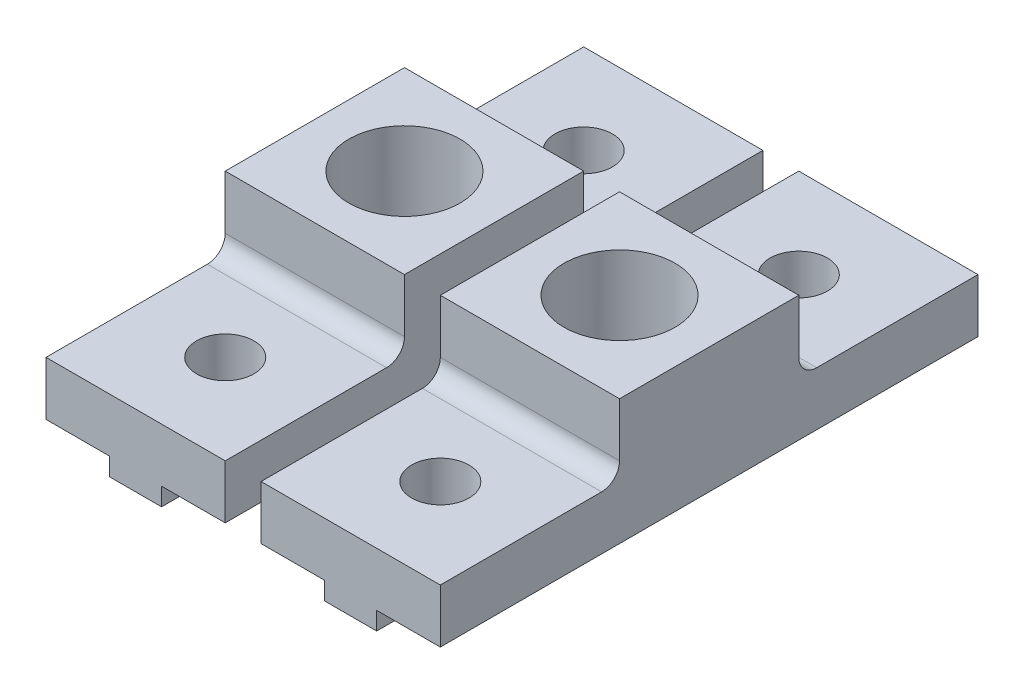
from build123d import *

# Parameters (mm, degrees)
BOSS_EXTRUDE1_DEPTH = 15
SKETCH2_R           = 3.1
SKETCH2_R_2         = 1.6
CUT_EXTRUDE1_DEPTH  = 9
SKETCH3_W           = 10
SKETCH3_H           = 10
CUT_EXTRUDE2_DEPTH  = 4
FILLET1_R           = 1
LPATTERN1_COUNT     = 2
LPATTERN1_PITCH     = 12


with BuildPart() as part:
    # Sketch1 → Boss-Extrude1 (new body, symmetric)
    with BuildSketch(Plane.XY):
        Polygon((-5, 0), (5, 0), (5, -7), (1.45, -7), (1.45, -8), (-1.45, -8), (-1.45, -7), (-5, -7), align=None)
    extrude(amount=BOSS_EXTRUDE1_DEPTH, both=True)

    # Sketch2 → Cut-Extrude1 (cut, through all)
    with BuildSketch(Plane(origin=(0, 0, 0), x_dir=(1, 0, 0), z_dir=(0, 1, 0))):
        Circle(SKETCH2_R)
        with Locations((0, 10)):
            Circle(SKETCH2_R_2)
        with Locations((0, -10)):
            Circle(SKETCH2_R_2)
    extrude(amount=-CUT_EXTRUDE1_DEPTH, mode=Mode.SUBTRACT)

    # Sketch3 → Cut-Extrude2 (cut)
    with BuildSketch(Plane(origin=(0, 0, 0), x_dir=(1, 0, 0), z_dir=(0, 1, 0))):
        with Locations((0, 10)):
            Rectangle(SKETCH3_W, SKETCH3_H)
        with Locations((0, -10)):
            Rectangle(SKETCH3_W, SKETCH3_H)
    extrude(amount=-CUT_EXTRUDE2_DEPTH, mode=Mode.SUBTRACT)

    # Fillet1
    fillet1_edges = [part.edges().sort_by_distance(p)[0] for p in [
        (0, -4, -5),
        (0, -4, 5),
    ]]
    fillet(fillet1_edges, radius=FILLET1_R)


with BuildPart() as lpattern1_1:
    # LPattern1: pattern copy
    add(part.part.moved(Location(Vector(-1, 0, 0) * (1 * LPATTERN1_PITCH))))


solid = Compound([part.part, lpattern1_1.part])
